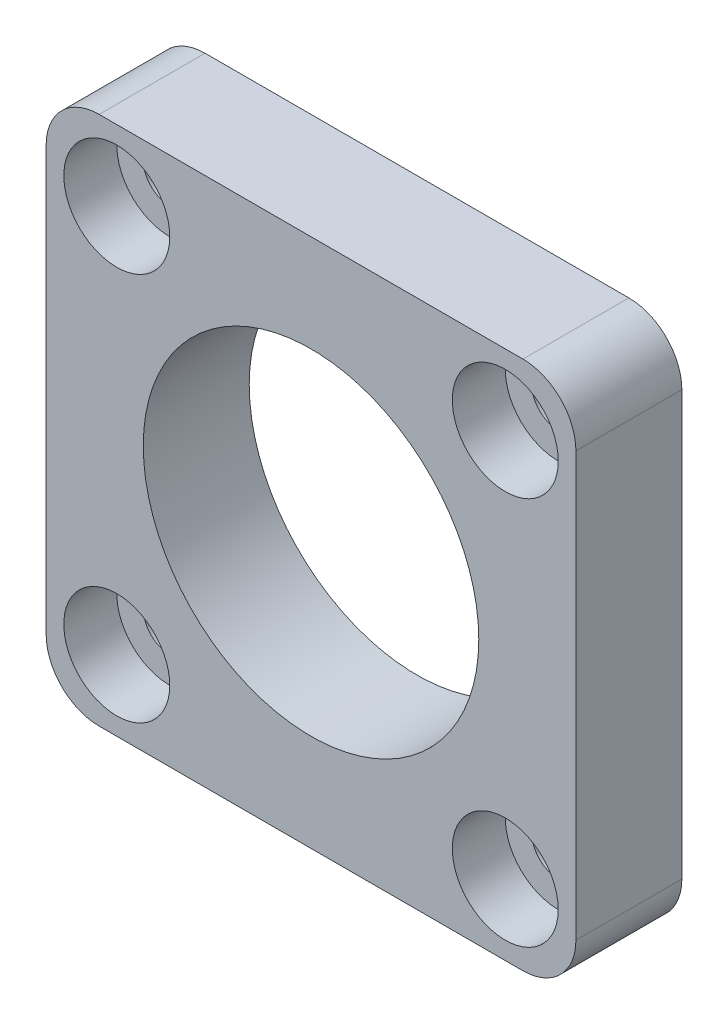
from build123d import *

# Parameters (mm, degrees)
SKETCH1_W           = 30
SKETCH1_H           = 30
SKETCH1_R           = 9.5
BOSS_EXTRUDE1_DEPTH = 6
SKETCH3_R           = 1.5
CUT_EXTRUDE2_DEPTH  = 7
SKETCH4_R           = 3
CUT_EXTRUDE3_DEPTH  = 3
FILLET1_R           = 3


with BuildPart() as part:
    # Sketch1 → Boss-Extrude1 (new body)
    with BuildSketch(Plane.XY):
        Rectangle(SKETCH1_W, SKETCH1_H)
        Circle(SKETCH1_R, mode=Mode.SUBTRACT)
    extrude(amount=BOSS_EXTRUDE1_DEPTH)

    # Sketch3 → Cut-Extrude2 (cut, through all)
    with BuildSketch(Plane.XY.offset(6)):
        with Locations((-11, 11)):
            Circle(SKETCH3_R)
        with Locations((11, 11)):
            Circle(SKETCH3_R)
        with Locations((11, -11)):
            Circle(SKETCH3_R)
        with Locations((-11, -11)):
            Circle(SKETCH3_R)
    extrude(amount=-CUT_EXTRUDE2_DEPTH, mode=Mode.SUBTRACT)

    # Sketch4 → Cut-Extrude3 (cut)
    with BuildSketch(Plane.XY.offset(6)):
        with Locations((-11, 11)):
            Circle(SKETCH4_R)
        with Locations((11, 11)):
            Circle(SKETCH4_R)
        with Locations((11, -11)):
            Circle(SKETCH4_R)
        with Locations((-11, -11)):
            Circle(SKETCH4_R)
    extrude(amount=-CUT_EXTRUDE3_DEPTH, mode=Mode.SUBTRACT)

    # Fillet1
    fillet1_edges = [part.edges().sort_by_distance(p)[0] for p in [
        (15, -15, 3),
        (-15, -15, 3),
        (-15, 15, 3),
        (15, 15, 3),
    ]]
    fillet(fillet1_edges, radius=FILLET1_R)


solid = part.part
